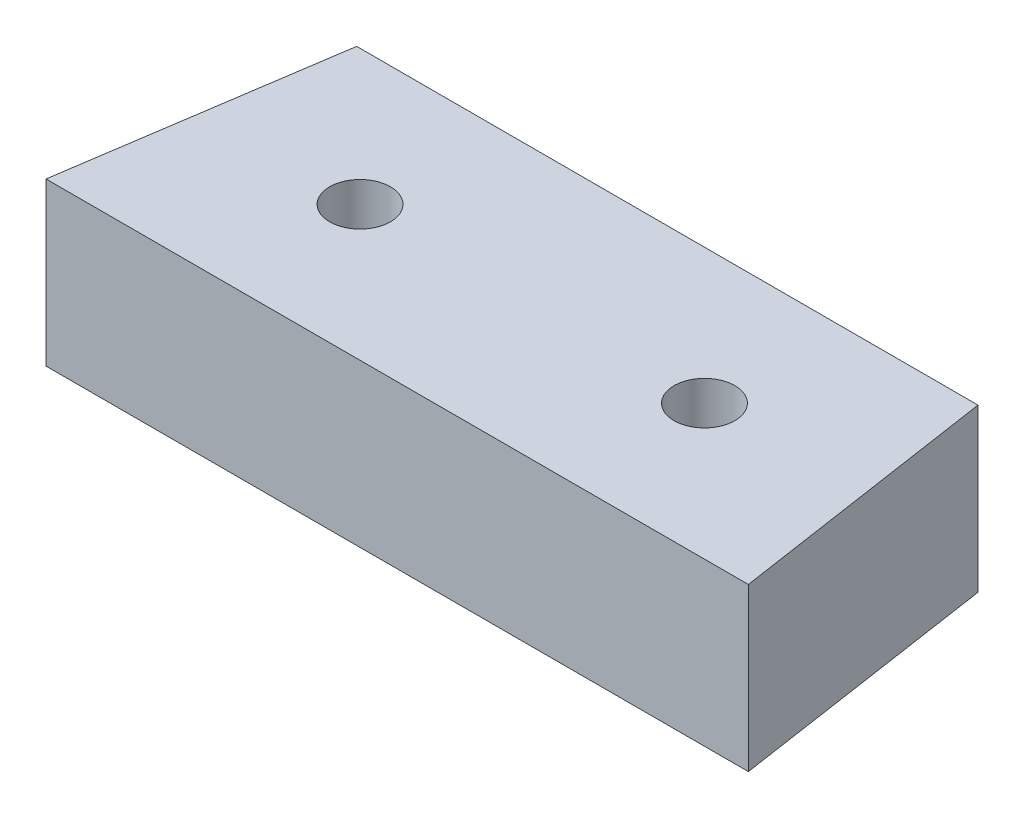
from build123d import *

# Parameters (mm, degrees)
SKETCH1_R           = 2.25
BOSS_EXTRUDE1_DEPTH = 12


with BuildPart() as part:
    # Sketch1 → Boss-Extrude1 (new body)
    with BuildSketch(Plane(origin=(0, 0, 0), x_dir=(1, 0, 0), z_dir=(0, 1, 0))):
        Polygon((-23, 10), (-26, -10), (26, -10), (23, 10), align=None)
        with Locations((-12.75, 0)):
            Circle(SKETCH1_R, mode=Mode.SUBTRACT)
        with Locations((12.75, 0)):
            Circle(SKETCH1_R, mode=Mode.SUBTRACT)
    extrude(amount=BOSS_EXTRUDE1_DEPTH)


solid = part.part
